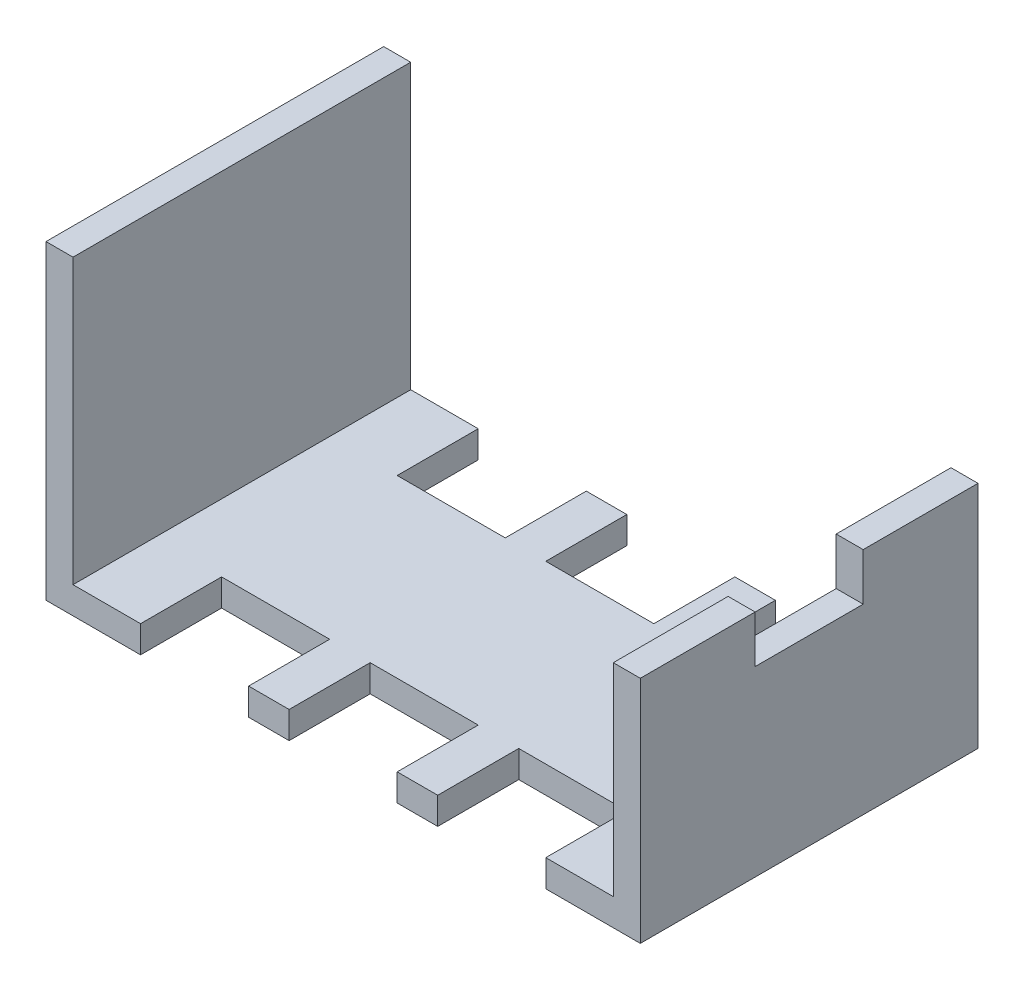
from build123d import *

# Parameters (mm, degrees)
SKETCH2_W           = 44
SKETCH2_H           = 29
BOSS_EXTRUDE1_DEPTH = 23
SKETCH3_W           = 40
SKETCH3_H           = 25
CUT_EXTRUDE1_DEPTH  = 21
SKETCH4_W           = 20.7
SKETCH4_H           = 2
CUT_EXTRUDE2_DEPTH  = 33
SKETCH5_W           = 30
SKETCH5_H           = 12.3
CUT_EXTRUDE3_DEPTH  = 2
CUT_EXTRUDE5_DEPTH  = 2
SKETCH11_W          = 3.9
SKETCH11_H          = 8.6
SKETCH11_W_2        = 7
SKETCH11_H_2        = 1.5
CUT_EXTRUDE6_DEPTH  = 2
SKETCH13_W          = 8
SKETCH13_H          = 6
CUT_EXTRUDE8_DEPTH  = 2
SKETCH14_W          = 44
SKETCH14_H          = 2
CUT_EXTRUDE9_DEPTH  = 23


with BuildPart() as part:
    # Sketch2 → Boss-Extrude1 (new body)
    with BuildSketch(Plane(origin=(0, 0, 0), x_dir=(1, 0, 0), z_dir=(0, 1, 0))):
        Rectangle(SKETCH2_W, SKETCH2_H)
    extrude(amount=BOSS_EXTRUDE1_DEPTH)

    # Sketch3 → Cut-Extrude1 (cut)
    with BuildSketch(Plane(origin=(0, 23, 0), x_dir=(1, 0, 0), z_dir=(0, 1, 0))):
        Rectangle(SKETCH3_W, SKETCH3_H)
    extrude(amount=-CUT_EXTRUDE1_DEPTH, mode=Mode.SUBTRACT)

    # Sketch4 → Cut-Extrude2 (cut)
    with BuildSketch(Plane.XY.offset(14.5)):
        with Locations((0.25, 18.2)):
            Rectangle(SKETCH4_W, SKETCH4_H)
    extrude(amount=-CUT_EXTRUDE2_DEPTH, mode=Mode.SUBTRACT)

    # Sketch5 → Cut-Extrude3 (cut)
    with BuildSketch(Plane.XY.offset(14.5)):
        with Locations((0, 8.15)):
            Rectangle(SKETCH5_W, SKETCH5_H)
    extrude(amount=-CUT_EXTRUDE3_DEPTH, mode=Mode.SUBTRACT)

    # Sketch8 → Cut-Extrude5 (cut)
    with BuildSketch(Plane(origin=(22, 0, 0), x_dir=(0, 0, -1), z_dir=(1, 0, 0))):
        Polygon((-12.5, 17), (-4, 17), (-4, 13.5), (4, 13.5), (4, 17), (12.5, 17), (12.5, 23), (-12.5, 23), align=None)
    extrude(amount=-CUT_EXTRUDE5_DEPTH, mode=Mode.SUBTRACT)

    # Sketch11 → Cut-Extrude6 (cut)
    with BuildSketch(Plane(origin=(0, 0, -14.5), x_dir=(-1, 0, 0), z_dir=(0, 0, -1))):
        with Locations((-18.05, 6.3)):
            Rectangle(SKETCH11_W, SKETCH11_H)
        with Locations((12.4, 2.75)):
            Rectangle(SKETCH11_W_2, SKETCH11_H_2)
    extrude(amount=-CUT_EXTRUDE6_DEPTH, mode=Mode.SUBTRACT)

    # Sketch13 → Cut-Extrude8 (cut)
    with BuildSketch(Plane(origin=(0, 2, 0), x_dir=(1, 0, 0), z_dir=(0, 1, 0))):
        with Locations((-11, -9.5)):
            Rectangle(SKETCH13_W, SKETCH13_H)
        with Locations((0, -9.5)):
            Rectangle(SKETCH13_W, SKETCH13_H)
        with Locations((11, 9.5)):
            Rectangle(SKETCH13_W, SKETCH13_H)
        with Locations((11, -9.5)):
            Rectangle(SKETCH13_W, SKETCH13_H)
        with Locations((-11, 9.5)):
            Rectangle(SKETCH13_W, SKETCH13_H)
        with Locations((0, 9.5)):
            Rectangle(SKETCH13_W, SKETCH13_H)
    extrude(amount=-CUT_EXTRUDE8_DEPTH, mode=Mode.SUBTRACT)

    # Sketch14 → Cut-Extrude9 (cut)
    with BuildSketch(Plane(origin=(0, 23, 0), x_dir=(1, 0, 0), z_dir=(0, 1, 0))):
        with Locations((0, -13.5)):
            Rectangle(SKETCH14_W, SKETCH14_H)
        with Locations((0, 13.5)):
            Rectangle(SKETCH14_W, SKETCH14_H)
    extrude(amount=-CUT_EXTRUDE9_DEPTH, mode=Mode.SUBTRACT)


solid = part.part
